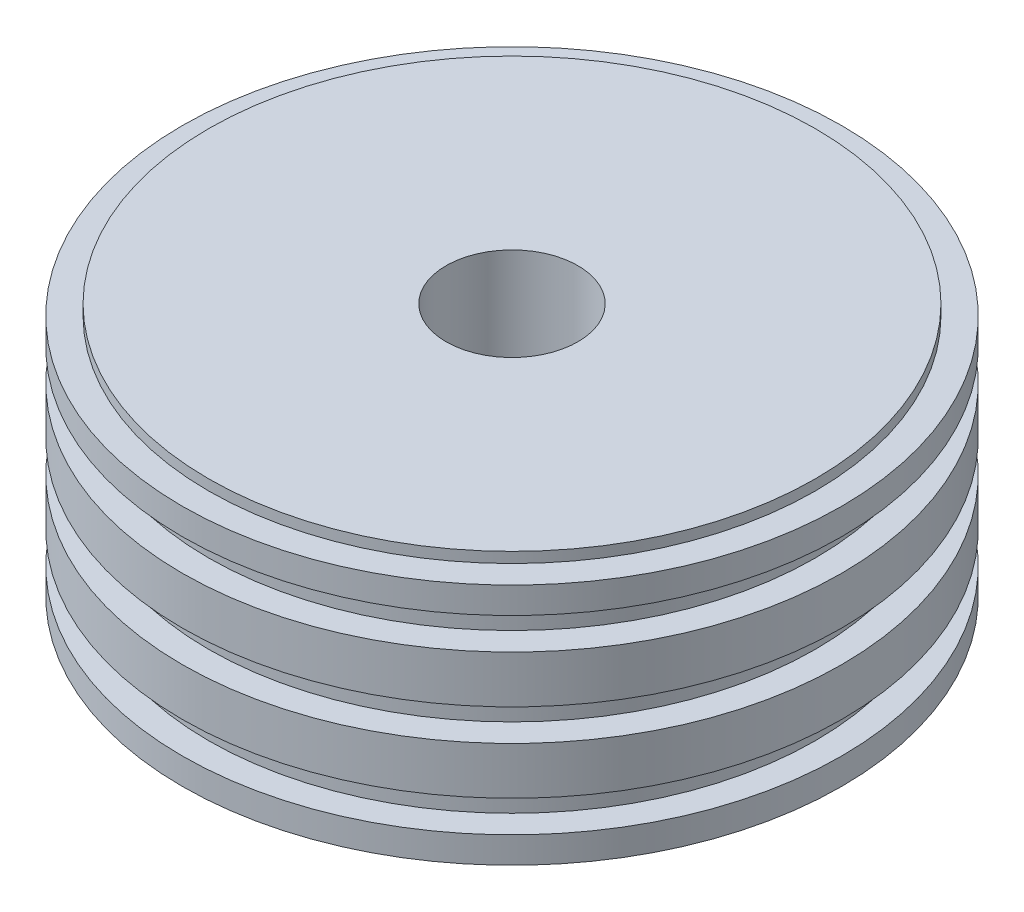
from build123d import *

# Parameters (mm, degrees)
SKETCH_1_R             = 62.5
EXTRUDE_1_DEPTH        = 50
CUT_EXTRUDE_START      = -7
SKETCH_2_R             = 62.5
SKETCH_2_R_2           = 57.5
CUT_EXTRUDE_1_DEPTH    = 6
PATTERN_LINEAR_1_COUNT = 3
PATTERN_LINEAR_1_PITCH = 15
SKETCH_3_R             = 62.5
SKETCH_3_R_2           = 57.5
CUT_EXTRUDE_2_DEPTH    = 2
SKETCH_4_R             = 62.5
SKETCH_4_R_2           = 57.5
CUT_EXTRUDE_3_DEPTH    = 2
SKETCH_5_R             = 12.5
CUT_EXTRUDE_4_DEPTH    = 51


with BuildPart() as part:
    # 草图1 → 凸台-拉伸1 (new body)
    with BuildSketch(Plane(origin=(0, 0, 0), x_dir=(1, 0, 0), z_dir=(0, 1, 0))):
        Circle(SKETCH_1_R)
    extrude(amount=EXTRUDE_1_DEPTH)

    # 草图2 → 切除-拉伸1 (cut)
    with BuildSketch(Plane(origin=(0, 50, 0), x_dir=(1, 0, 0), z_dir=(0, 1, 0)).offset(CUT_EXTRUDE_START)):
        Circle(SKETCH_2_R)
        Circle(SKETCH_2_R_2, mode=Mode.SUBTRACT)
    cut_extrude_1 = extrude(amount=-CUT_EXTRUDE_1_DEPTH, mode=Mode.SUBTRACT)

    # 阵列(线性)1: 切除-拉伸1 ×3
    with Locations(*[(0, -i * PATTERN_LINEAR_1_PITCH, 0) for i in range(1, PATTERN_LINEAR_1_COUNT)]):
        add(cut_extrude_1, mode=Mode.SUBTRACT)

    # 草图3 → 切除-拉伸2 (cut)
    with BuildSketch(Plane(origin=(0, 50, 0), x_dir=(1, 0, 0), z_dir=(0, 1, 0))):
        Circle(SKETCH_3_R)
        Circle(SKETCH_3_R_2, mode=Mode.SUBTRACT)
    extrude(amount=-CUT_EXTRUDE_2_DEPTH, mode=Mode.SUBTRACT)

    # 草图4 → 切除-拉伸3 (cut)
    with BuildSketch(Plane.XZ):
        Circle(SKETCH_4_R)
        Circle(SKETCH_4_R_2, mode=Mode.SUBTRACT)
    extrude(amount=-CUT_EXTRUDE_3_DEPTH, mode=Mode.SUBTRACT)

    # 草图5 → 切除-拉伸4 (cut, through all)
    with BuildSketch(Plane(origin=(0, 50, 0), x_dir=(1, 0, 0), z_dir=(0, 1, 0))):
        Circle(SKETCH_5_R)
    extrude(amount=-CUT_EXTRUDE_4_DEPTH, mode=Mode.SUBTRACT)


solid = part.part
